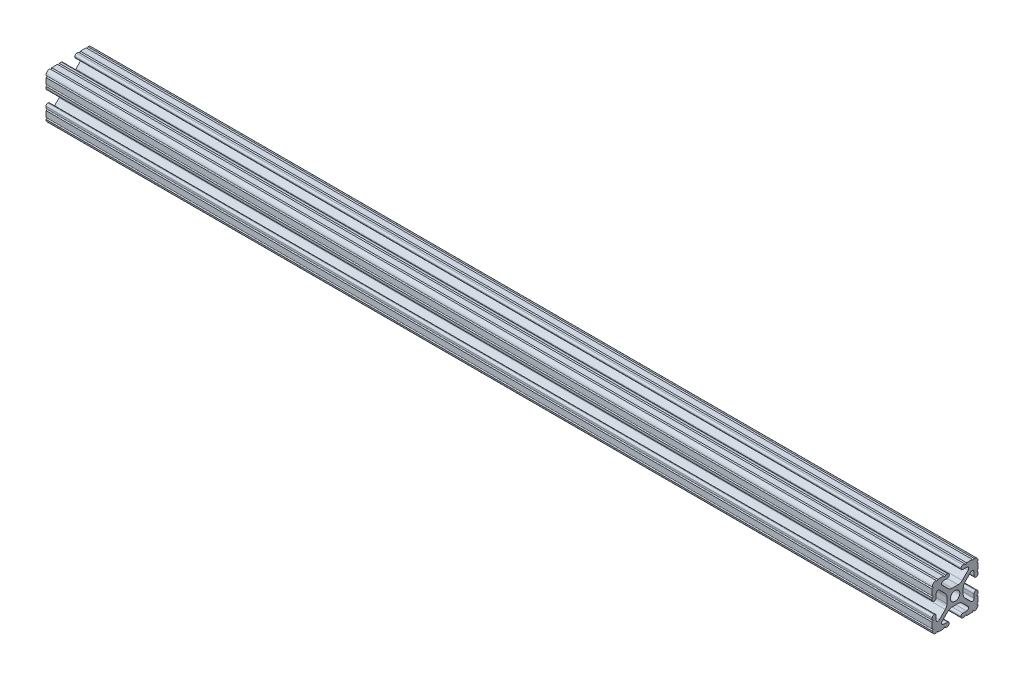
from build123d import *

# Parameters (mm, degrees)
SKETCH14_R                = 2.6035
F_10_1010_PROFILE_1_DEPTH = 491.49


with BuildPart() as part:
    # Sketch14 → 10 1010 PROFILE(1) (new body)
    with BuildSketch(Plane.ZY):
        with BuildLine():
            Line((-1.709253557, -4.4958), (1.709253557, -4.4958))
            ThreePointArc((1.709253557, -4.4958), (2.922935876, -4.736928798), (3.95226937, -5.423689619))
            Line((3.95226937, -5.423689619), (7.179652728, -8.645192207))
            ThreePointArc((7.179652728, -8.645192207), (7.414733441, -9.822812921), (6.41641086, -10.4902))
            Line((6.41641086, -10.4902), (4.28752, -10.4902))
            ThreePointArc((4.28752, -10.4902), (3.545750844, -10.797450844), (3.2385, -11.53922))
            Line((3.2385, -11.53922), (3.2385, -11.65098))
            ThreePointArc((3.2385, -11.65098), (3.545750844, -12.392749156), (4.28752, -12.7))
            Line((4.28752, -12.7), (5.3171344, -12.7))
            ThreePointArc((5.3171344, -12.7), (5.8251344, -12.192), (6.3331344, -12.7))
            Line((6.3331344, -12.7), (9.5504, -12.7))
            ThreePointArc((9.5504, -12.7), (10.058323491, -12.192000006), (10.566399977, -12.699846982))
            ThreePointArc((10.566399977, -12.699846982), (12.082522516, -12.082522516), (12.699846982, -10.566399977))
            ThreePointArc((12.699846982, -10.566399977), (12.192000006, -10.058323491), (12.7, -9.5504))
            Line((12.7, -9.5504), (12.7, -6.3330836))
            ThreePointArc((12.7, -6.3330836), (12.192, -5.8250836), (12.7, -5.3170836))
            Line((12.7, -5.3170836), (12.7, -4.287470133))
            ThreePointArc((12.7, -4.287470133), (12.392749156, -3.545700977), (11.65098, -3.238450133))
            Line((11.65098, -3.238450133), (11.53922, -3.238450133))
            ThreePointArc((11.53922, -3.238450133), (10.797450844, -3.545700977), (10.4902, -4.287470133))
            Line((10.4902, -4.287470133), (10.4902, -6.402089023))
            ThreePointArc((10.4902, -6.402089023), (9.856394933, -7.351113629), (8.736962546, -7.129240479))
            Line((8.736962546, -7.129240479), (5.440484187, -3.838768792))
            ThreePointArc((5.440484187, -3.838768792), (4.75073678, -2.808015636), (4.5085, -1.591658411))
            Line((4.5085, -1.591658411), (4.5085, 1.591658411))
            ThreePointArc((4.5085, 1.591658411), (4.75073678, 2.808015636), (5.440484187, 3.838768792))
            Line((5.440484187, 3.838768792), (8.736962546, 7.129240479))
            ThreePointArc((8.736962546, 7.129240479), (9.856394933, 7.351113629), (10.4902, 6.402089023))
            Line((10.4902, 6.402089023), (10.4902, 4.287470133))
            ThreePointArc((10.4902, 4.287470133), (10.797450844, 3.545700977), (11.53922, 3.238450133))
            Line((11.53922, 3.238450133), (11.65098, 3.238450133))
            ThreePointArc((11.65098, 3.238450133), (12.392749156, 3.545700977), (12.7, 4.287470133))
            Line((12.7, 4.287470133), (12.7, 5.3171344))
            ThreePointArc((12.7, 5.3171344), (12.192, 5.8251344), (12.7, 6.3331344))
            Line((12.7, 6.3331344), (12.7, 9.5504))
            ThreePointArc((12.7, 9.5504), (12.192000006, 10.058323491), (12.699846982, 10.566399977))
            ThreePointArc((12.699846982, 10.566399977), (12.082522516, 12.082522516), (10.566399977, 12.699846982))
            ThreePointArc((10.566399977, 12.699846982), (10.058323491, 12.192000006), (9.5504, 12.7))
            Line((9.5504, 12.7), (6.3330836, 12.7))
            ThreePointArc((6.3330836, 12.7), (5.8250836, 12.192), (5.3170836, 12.7))
            Line((5.3170836, 12.7), (4.2874692, 12.7))
            ThreePointArc((4.2874692, 12.7), (3.545700044, 12.392749156), (3.2384492, 11.65098))
            Line((3.2384492, 11.65098), (3.2384492, 11.53922))
            ThreePointArc((3.2384492, 11.53922), (3.545700044, 10.797450844), (4.2874692, 10.4902))
            Line((4.2874692, 10.4902), (6.476774195, 10.4902))
            ThreePointArc((6.476774195, 10.4902), (7.43216212, 9.851515102), (7.207191475, 8.724540082))
            Line((7.207191475, 8.724540082), (3.900315394, 5.423689619))
            ThreePointArc((3.900315394, 5.423689619), (2.8709819, 4.736928798), (1.657299581, 4.4958))
            Line((1.657299581, 4.4958), (-1.657299581, 4.4958))
            ThreePointArc((-1.657299581, 4.4958), (-2.8709819, 4.736928798), (-3.900315394, 5.423689619))
            Line((-3.900315394, 5.423689619), (-7.207191475, 8.724540082))
            ThreePointArc((-7.207191475, 8.724540082), (-7.43216212, 9.851515102), (-6.476774195, 10.4902))
            Line((-6.476774195, 10.4902), (-4.2874692, 10.4902))
            ThreePointArc((-4.2874692, 10.4902), (-3.545700044, 10.797450844), (-3.2384492, 11.53922))
            Line((-3.2384492, 11.53922), (-3.2384492, 11.65098))
            ThreePointArc((-3.2384492, 11.65098), (-3.545700044, 12.392749156), (-4.2874692, 12.7))
            Line((-4.2874692, 12.7), (-5.3170836, 12.7))
            ThreePointArc((-5.3170836, 12.7), (-5.8250836, 12.192), (-6.3330836, 12.7))
            Line((-6.3330836, 12.7), (-9.5504, 12.7))
            ThreePointArc((-9.5504, 12.7), (-10.058323491, 12.192000006), (-10.566399977, 12.699846982))
            ThreePointArc((-10.566399977, 12.699846982), (-12.082522516, 12.082522516), (-12.699846982, 10.566399977))
            ThreePointArc((-12.699846982, 10.566399977), (-12.192000006, 10.058323491), (-12.7, 9.5504))
            Line((-12.7, 9.5504), (-12.7, 6.3331344))
            ThreePointArc((-12.7, 6.3331344), (-12.192, 5.8251344), (-12.7, 5.3171344))
            Line((-12.7, 5.3171344), (-12.7, 4.287470133))
            ThreePointArc((-12.7, 4.287470133), (-12.392749156, 3.545700977), (-11.65098, 3.238450133))
            Line((-11.65098, 3.238450133), (-11.53922, 3.238450133))
            ThreePointArc((-11.53922, 3.238450133), (-10.797450844, 3.545700977), (-10.4902, 4.287470133))
            Line((-10.4902, 4.287470133), (-10.4902, 6.402089023))
            ThreePointArc((-10.4902, 6.402089023), (-9.856394933, 7.351113629), (-8.736962546, 7.129240479))
            Line((-8.736962546, 7.129240479), (-5.440484187, 3.838768792))
            ThreePointArc((-5.440484187, 3.838768792), (-4.75073678, 2.808015636), (-4.5085, 1.591658411))
            Line((-4.5085, 1.591658411), (-4.5085, -1.591658411))
            ThreePointArc((-4.5085, -1.591658411), (-4.75073678, -2.808015636), (-5.440484187, -3.838768792))
            Line((-5.440484187, -3.838768792), (-8.736962546, -7.129240479))
            ThreePointArc((-8.736962546, -7.129240479), (-9.856394933, -7.351113629), (-10.4902, -6.402089023))
            Line((-10.4902, -6.402089023), (-10.4902, -4.287470133))
            ThreePointArc((-10.4902, -4.287470133), (-10.797450844, -3.545700977), (-11.53922, -3.238450133))
            Line((-11.53922, -3.238450133), (-11.65098, -3.238450133))
            ThreePointArc((-11.65098, -3.238450133), (-12.392749156, -3.545700977), (-12.7, -4.287470133))
            Line((-12.7, -4.287470133), (-12.7, -5.3170836))
            ThreePointArc((-12.7, -5.3170836), (-12.192, -5.8250836), (-12.7, -6.3330836))
            Line((-12.7, -6.3330836), (-12.7, -9.5504))
            ThreePointArc((-12.7, -9.5504), (-12.192000006, -10.058323491), (-12.699846982, -10.566399977))
            ThreePointArc((-12.699846982, -10.566399977), (-12.082522516, -12.082522516), (-10.566399977, -12.699846982))
            ThreePointArc((-10.566399977, -12.699846982), (-10.058323491, -12.192000006), (-9.5504, -12.7))
            Line((-9.5504, -12.7), (-6.3331344, -12.7))
            ThreePointArc((-6.3331344, -12.7), (-5.8251344, -12.192), (-5.3171344, -12.7))
            Line((-5.3171344, -12.7), (-4.28752, -12.7))
            ThreePointArc((-4.28752, -12.7), (-3.545750844, -12.392749156), (-3.2385, -11.65098))
            Line((-3.2385, -11.65098), (-3.2385, -11.53922))
            ThreePointArc((-3.2385, -11.53922), (-3.545750844, -10.797450844), (-4.28752, -10.4902))
            Line((-4.28752, -10.4902), (-6.41641086, -10.4902))
            ThreePointArc((-6.41641086, -10.4902), (-7.414733441, -9.822812921), (-7.179652728, -8.645192207))
            Line((-7.179652728, -8.645192207), (-3.95226937, -5.423689619))
            ThreePointArc((-3.95226937, -5.423689619), (-2.922935876, -4.736928798), (-1.709253557, -4.4958))
        make_face()
        Circle(SKETCH14_R, mode=Mode.SUBTRACT)
    extrude(amount=F_10_1010_PROFILE_1_DEPTH)


solid = part.part
